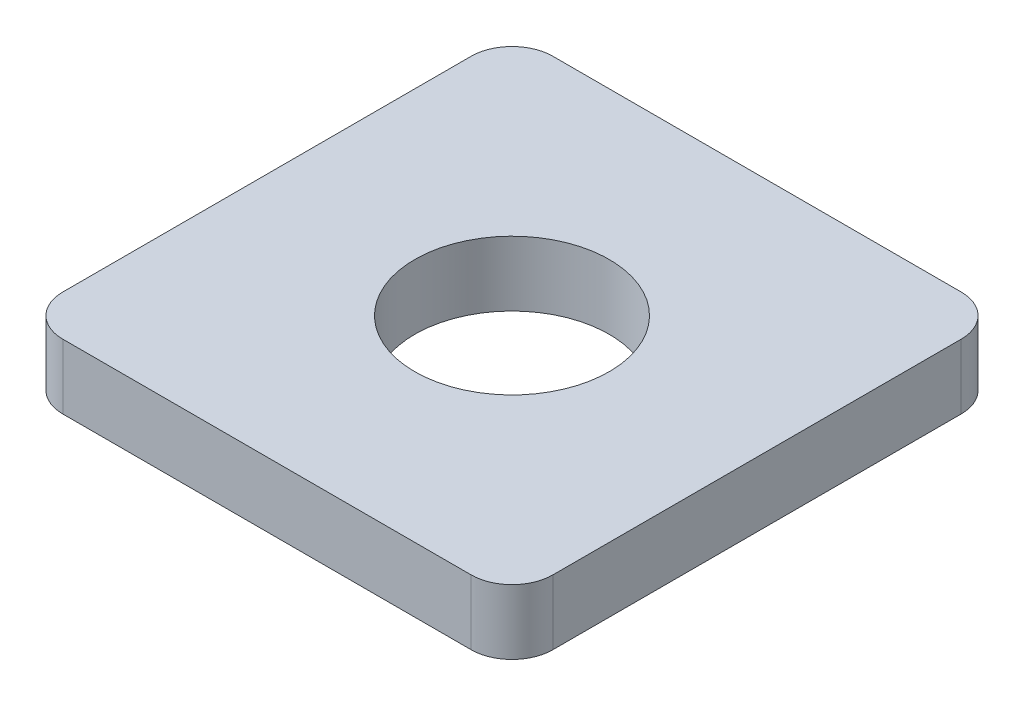
from build123d import *

# Parameters (mm, degrees)
SKETCH1_W           = 12
SKETCH1_H           = 12
SKETCH1_R           = 2.38125
BOSS_EXTRUDE1_DEPTH = 1.5875
FILLET1_R           = 1


with BuildPart() as part:
    # Sketch1 → Boss-Extrude1 (new body)
    with BuildSketch(Plane(origin=(0, 0, 0), x_dir=(1, 0, 0), z_dir=(0, 1, 0))):
        Rectangle(SKETCH1_W, SKETCH1_H)
        Circle(SKETCH1_R, mode=Mode.SUBTRACT)
    extrude(amount=BOSS_EXTRUDE1_DEPTH)

    # Fillet1
    fillet1_edges = [part.edges().sort_by_distance(p)[0] for p in [
        (-6, 0.79375, -6),
        (6, 0.79375, -6),
        (6, 0.79375, 6),
        (-6, 0.79375, 6),
    ]]
    fillet(fillet1_edges, radius=FILLET1_R)


solid = part.part
